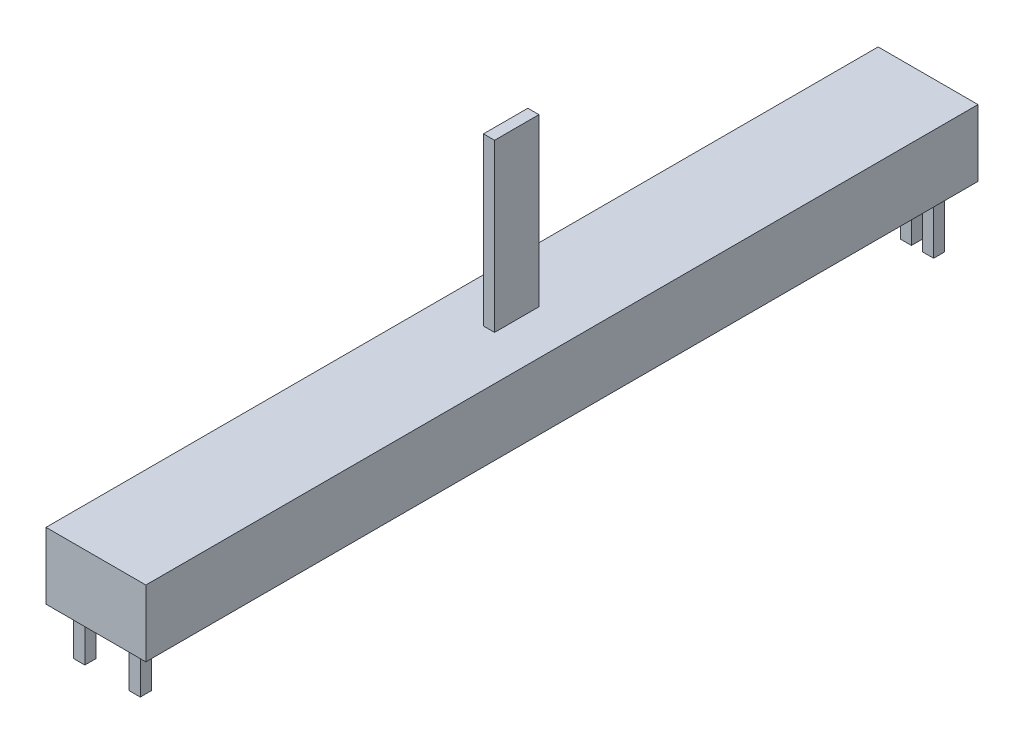
from build123d import *

# Parameters (mm, degrees)
SKETCH1_W           = 9
SKETCH1_H           = 75
BOSS_EXTRUDE1_DEPTH = 6
SKETCH2_W           = 1
SKETCH2_H           = 4
BOSS_EXTRUDE2_DEPTH = 15
SKETCH4_W           = 1
SKETCH4_H           = 1
BOSS_EXTRUDE3_DEPTH = 5


with BuildPart() as part:
    # Sketch1 → Boss-Extrude1 (new body)
    with BuildSketch(Plane(origin=(0, 0, 0), x_dir=(1, 0, 0), z_dir=(0, 1, 0))):
        Rectangle(SKETCH1_W, SKETCH1_H)
    extrude(amount=BOSS_EXTRUDE1_DEPTH)

    # Sketch2 → Boss-Extrude2 (add)
    with BuildSketch(Plane(origin=(0, 6, 0), x_dir=(1, 0, 0), z_dir=(0, 1, 0))):
        with Locations((0, -0.071668646)):
            Rectangle(SKETCH2_W, SKETCH2_H)
    extrude(amount=BOSS_EXTRUDE2_DEPTH)

    # Sketch4 → Boss-Extrude3 (add)
    with BuildSketch(Plane.XZ):
        with Locations((-3.5, 35)):
            Rectangle(SKETCH4_W, SKETCH4_H)
        with Locations((1.5, 35)):
            Rectangle(SKETCH4_W, SKETCH4_H)
        with Locations((-3, -35)):
            Rectangle(SKETCH4_W, SKETCH4_H)
        with Locations((-1, -35)):
            Rectangle(SKETCH4_W, SKETCH4_H)
        with Locations((1, -35)):
            Rectangle(SKETCH4_W, SKETCH4_H)
        with Locations((3, -35)):
            Rectangle(SKETCH4_W, SKETCH4_H)
    extrude(amount=BOSS_EXTRUDE3_DEPTH)


solid = part.part
